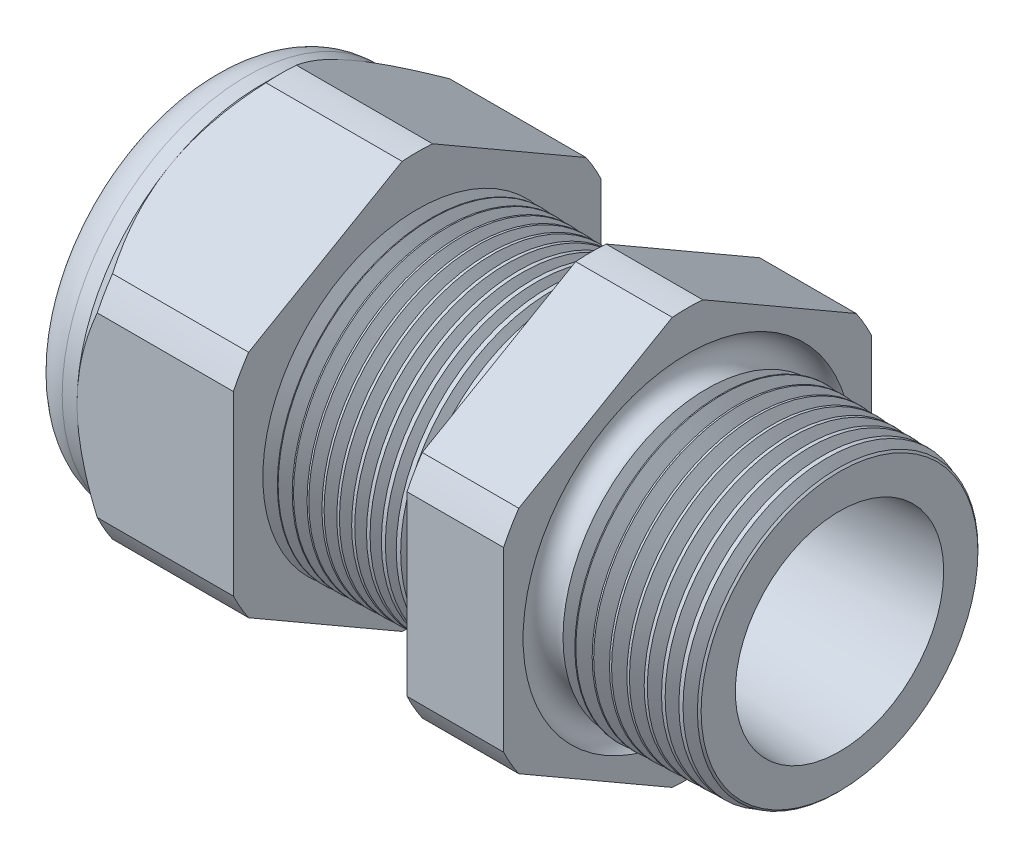
from build123d import *

# Parameters (mm, degrees)
SKETCH12_OUTSIDE_W = 52.712
SKETCH12_OUTSIDE_H = 52.712
CUT_EXTRUDE2_DEPTH = 30.966
FILLET4_R          = 2.032
SKETCH19_OUTSIDE_W = 33.73
SKETCH19_OUTSIDE_H = 35.826
SKETCH19_OUTSIDE_R = 9.525
CUT_EXTRUDE3_DEPTH = 1.999996
CUT_EXTRUDE3_DRAFT = -45
CHAMFER1_SIZE      = 0.260919487
CHAMFER1_SIZE2     = 0.254
SKETCH21_R         = 3.937
PLUG_DEPTH         = 3.81
SKETCH22_R         = 3.683
CUT_EXTRUDE4_DEPTH = 0.508
SKETCH27_R         = 0.889
PLUGHOLES_DEPTH    = 33.258
CIRPATTERN1_COUNT  = 3
LPATTERN1_COUNT    = 12
LPATTERN1_PITCH    = 0.762
LPATTERN2_COUNT    = 9
LPATTERN2_PITCH    = 0.889
SKETCH32_R         = 0.889


with BuildPart() as part:
    # Sketch10 → Revolve2 (revolve)
    with BuildSketch(Plane.XY, mode=Mode.PRIVATE) as revolve2_sk:
        Polygon((-32.766, 3.937), (-21.866, 3.937), (0, 5.396418639), (0, 7.428418639), (-7.874, 7.634606585), (-7.874, 19.05), (-12.874, 19.05), (-12.874, 7.765536193), (-21.866, 8.001), (-21.866, 19.05), (-29.966, 19.05), (-29.966, 9.525), (-32.766, 9.525), align=None)
    revolve(revolve2_sk.sketch.rotate(Axis((0, 0, 0), (-1, 0, 0)), 90), axis=Axis((0, 0, 0), (-1, 0, 0)))  # turned: the seam where the file's is

    # Sketch12 outside → Cut-Extrude2 (cut, through all)
    with BuildSketch(Plane.ZY.offset(29.966)):
        Rectangle(SKETCH12_OUTSIDE_W, SKETCH12_OUTSIDE_H)
        with BuildLine():
            Line((-0.788451287, 10.543310065), (-8.736548713, 5.954473877))
            ThreePointArc((-8.736548713, 5.954473877), (-9.156270088, 5.286375), (-9.525, 4.588836188))
            Line((-9.525, 4.588836188), (-9.525, -4.588836188))
            ThreePointArc((-9.525, -4.588836188), (-9.156270088, -5.286375), (-8.736548713, -5.954473877))
            Line((-8.736548713, -5.954473877), (-0.788451287, -10.543310065))
            ThreePointArc((-0.788451287, -10.543310065), (0, -10.57275), (0.788451287, -10.543310065))
            Line((0.788451287, -10.543310065), (8.736548713, -5.954473877))
            ThreePointArc((8.736548713, -5.954473877), (9.156270088, -5.286375), (9.525, -4.588836188))
            Line((9.525, -4.588836188), (9.525, 4.588836188))
            ThreePointArc((9.525, 4.588836188), (9.156270088, 5.286375), (8.736548713, 5.954473877))
            Line((8.736548713, 5.954473877), (0.788451287, 10.543310065))
            ThreePointArc((0.788451287, 10.543310065), (0, 10.57275), (-0.788451287, 10.543310065))
        make_face(mode=Mode.SUBTRACT)
    extrude(amount=-CUT_EXTRUDE2_DEPTH, mode=Mode.SUBTRACT)

    # Fillet4
    fillet4_edges = [part.edges().sort_by_distance(p)[0] for p in [
        (-32.766, 0, 9.525),
    ]]
    fillet(fillet4_edges, radius=FILLET4_R)


with BuildPart() as cut_extrude3_tool:
    # Sketch19 outside → Cut-Extrude3 (with draft: the straight prism first)
    with BuildSketch(Plane.ZY.offset(29.966)):
        Rectangle(SKETCH19_OUTSIDE_W, SKETCH19_OUTSIDE_H)
        Circle(SKETCH19_OUTSIDE_R, mode=Mode.SUBTRACT)
    extrude(amount=-CUT_EXTRUDE3_DEPTH)
    # Cut-Extrude3: the draft: its side faces are tilted about the plane it starts from
    cut_extrude3_sides = [cut_extrude3_tool.faces().sort_by_distance(p)[0] for p in [
        (-28.966002, -17.913, 0),
        (-28.966002, 0, 16.865),
        (-28.966002, 17.913, 0),
        (-28.966002, 0, -16.865),
        (-28.966002, 0, -9.525),
    ]]
    draft(cut_extrude3_sides, Plane.ZY.offset(29.966), CUT_EXTRUDE3_DRAFT)


with BuildPart() as part_1:
    add(part.part)

    # Cut-Extrude3: cut by cut_extrude3_tool
    add(cut_extrude3_tool.part, mode=Mode.SUBTRACT)

    # Chamfer1
    chamfer1_edges = [part_1.edges().sort_by_distance(p)[0] for p in [
        (0, 0, 7.428418639),
    ]]
    chamfer1_side = [part_1.faces().sort_by_distance(p)[0] for p in [
        (0, 0, 5.606526047),
    ]]
    chamfer(chamfer1_edges, length=CHAMFER1_SIZE, length2=CHAMFER1_SIZE2, reference=chamfer1_side[0])

    # Sketch29 → Cut-Revolve1 (revolve, cut)
    with BuildSketch(Plane.XY, mode=Mode.PRIVATE) as cut_revolve1_sk:
        Polygon((-21.866, 8.001), (-21.133016419, 7.981806149), (-21.516130572, 7.356620673), align=None)
    cut_revolve1 = revolve(cut_revolve1_sk.sketch.rotate(Axis((0, 0, 0), (-1, 0, 0)), 90), axis=Axis((0, 0, 0), (-1, 0, 0)), mode=Mode.SUBTRACT)  # turned: the seam where the file's is

    # LPattern1: Cut-Revolve1 ×12
    with Locations(*[(i * LPATTERN1_PITCH, 0, 0) for i in range(1, LPATTERN1_COUNT)]):
        add(cut_revolve1, mode=Mode.SUBTRACT)

    # Sketch30 → Cut-Revolve2 (revolve, cut)
    with BuildSketch(Plane.XY, mode=Mode.PRIVATE) as cut_revolve2_sk:
        Polygon((-7.874, 7.634606585), (-6.994419703, 7.611573965), (-7.454156686, 6.861351393), align=None)
    cut_revolve2 = revolve(cut_revolve2_sk.sketch.rotate(Axis((0, 0, 0), (-1, 0, 0)), 270), axis=Axis((0, 0, 0), (-1, 0, 0)), mode=Mode.SUBTRACT)  # turned: the seam where the file's is

    # LPattern2: Cut-Revolve2 ×9
    with Locations(*[(i * LPATTERN2_PITCH, 0, 0) for i in range(1, LPATTERN2_COUNT)]):
        add(cut_revolve2, mode=Mode.SUBTRACT)

    # Sketch32 → Cut-Revolve3 (revolve, cut)
    with BuildSketch(Plane.XY, mode=Mode.PRIVATE) as cut_revolve3_sk:
        with Locations((-7.747, 7.634606585)):
            Circle(SKETCH32_R)
    revolve(cut_revolve3_sk.sketch.rotate(Axis((0, 0, 0), (-1, 0, 0)), 270), axis=Axis((0, 0, 0), (-1, 0, 0)), mode=Mode.SUBTRACT)  # turned: the seam where the file's is


with BuildPart() as body_2:
    # Sketch21 → plug (new body)
    with BuildSketch(Plane.ZY.offset(32.766)):
        Circle(SKETCH21_R)
    extrude(amount=-PLUG_DEPTH)

    # Sketch22 → Cut-Extrude4 (cut)
    with BuildSketch(Plane.ZY.offset(32.766)):
        Circle(SKETCH22_R)
    extrude(amount=-CUT_EXTRUDE4_DEPTH, mode=Mode.SUBTRACT)

    # Sketch27 → plugholes (cut, through all)
    with BuildSketch(Plane.ZY.offset(32.258)):
        with Locations((-2.790444, 0)):
            Circle(SKETCH27_R)
    plugholes = extrude(amount=-PLUGHOLES_DEPTH, mode=Mode.SUBTRACT)

    # CirPattern1: plugholes ×3 about axis
    cirpattern1_axis = Axis((0, 0, 0), (1, 0, 0))
    for i in range(1, CIRPATTERN1_COUNT):
        add(plugholes.rotate(cirpattern1_axis, i * 360 / CIRPATTERN1_COUNT), mode=Mode.SUBTRACT)


solid = Compound([part_1.part, body_2.part])
